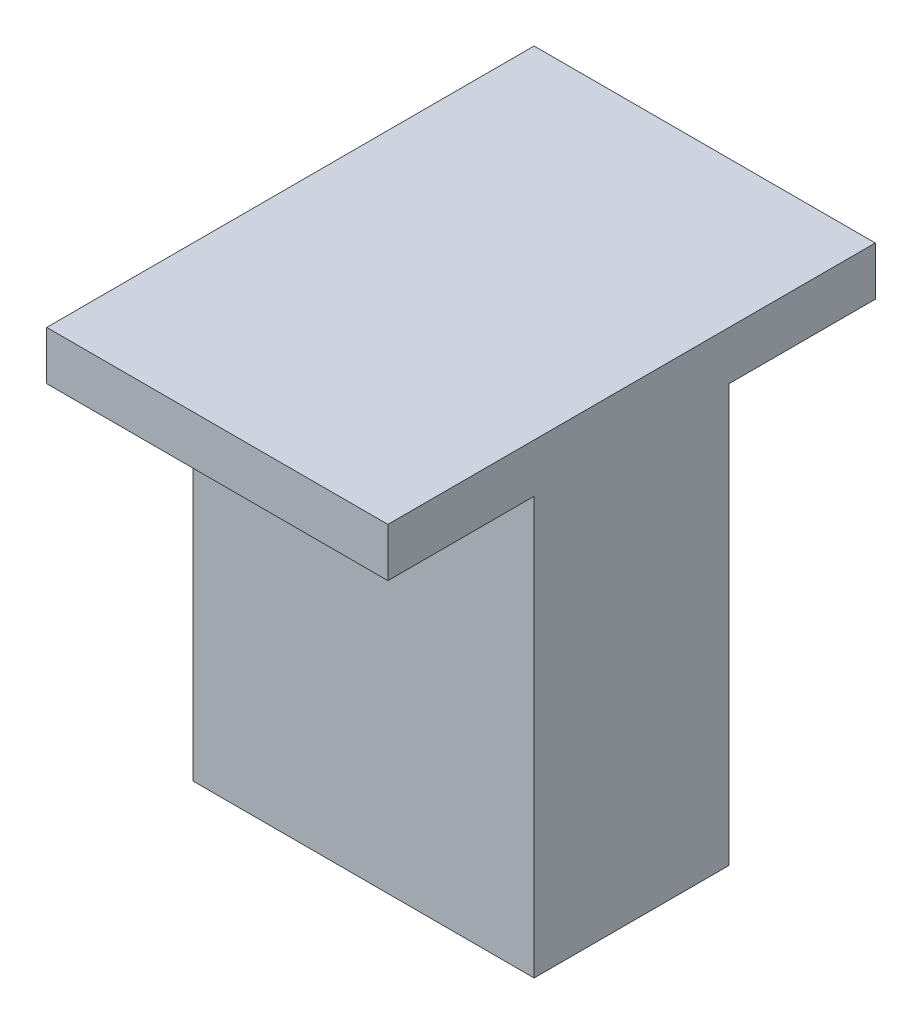
from build123d import *

# Parameters (mm, degrees)
SKETCH2_W           = 35
SKETCH2_H           = 20
BOSS_EXTRUDE1_DEPTH = 47.8
SKETCH3_W           = 35
SKETCH3_H           = 50
BOSS_EXTRUDE2_DEPTH = 5


with BuildPart() as part:
    # Sketch2 → Boss-Extrude1 (new body)
    with BuildSketch(Plane(origin=(0, 0, 0), x_dir=(1, 0, 0), z_dir=(0, 1, 0))):
        Rectangle(SKETCH2_W, SKETCH2_H)
    extrude(amount=BOSS_EXTRUDE1_DEPTH)

    # Sketch3 → Boss-Extrude2 (add)
    with BuildSketch(Plane(origin=(0, 47.8, 0), x_dir=(1, 0, 0), z_dir=(0, 1, 0))):
        Rectangle(SKETCH3_W, SKETCH3_H)
    extrude(amount=-BOSS_EXTRUDE2_DEPTH)


solid = part.part
